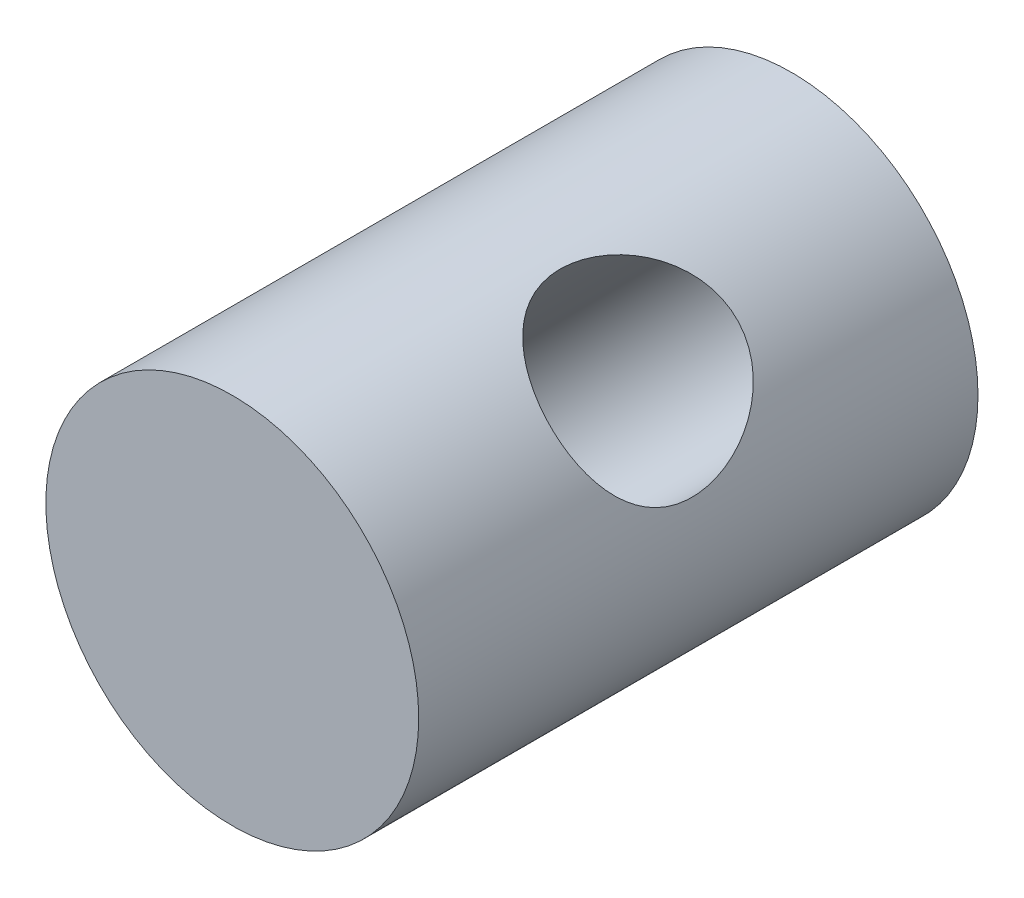
from build123d import *

# Parameters (mm, degrees)
SKETCH1_R           = 4
BOSS_EXTRUDE1_DEPTH = 12
SKETCH2_R           = 2
CUT_EXTRUDE1_DEPTH  = 10.656854249


with BuildPart() as part:
    # Sketch1 → Boss-Extrude1 (new body)
    with BuildSketch(Plane.XY):
        Circle(SKETCH1_R)
    extrude(amount=BOSS_EXTRUDE1_DEPTH)

    # Sketch2 → Cut-Extrude1 (cut, through all)
    with BuildSketch(Plane(origin=(2.828427125, 2.828427125, 0), x_dir=(0.707106781, -0.707106781, 0), z_dir=(0.707106781, 0.707106781, 0))):
        with Locations((0, -6)):
            Circle(SKETCH2_R)
    extrude(amount=-CUT_EXTRUDE1_DEPTH, mode=Mode.SUBTRACT)


solid = part.part
